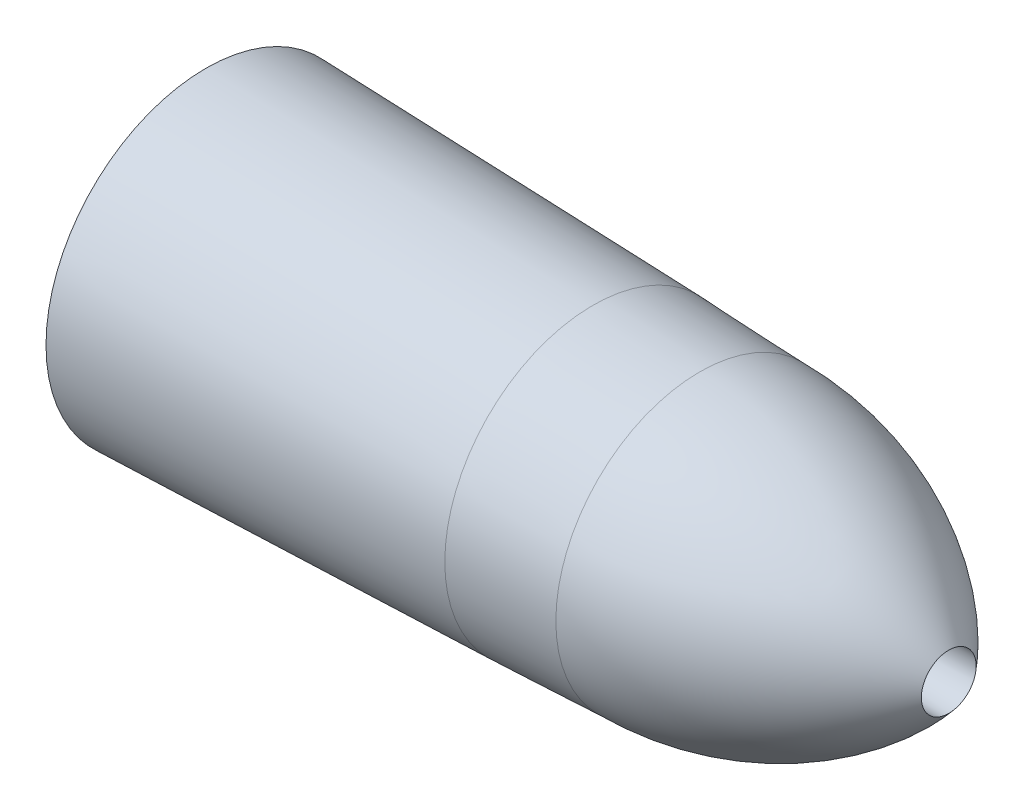
from build123d import *


with BuildPart() as part:
    # Sketch1 → Revolve1 (revolve)
    with BuildSketch(Plane(origin=(0, 0, 0), x_dir=(1, 0, 0), z_dir=(0, 1, 0))):
        Polygon((-355, 76.3943727), (-355, 12.3), (-170, 12.716901408), (-170, 70.8239497), align=None)
        Polygon((-170, 70.8239497), (-170, 12.716901408), (-119, 12.831830986), (-119, 68.7549354), align=None)
        with BuildLine():
            Line((-119, 68.7549354), (-119, 12.831830986))
            Line((-119, 12.831830986), (0, 13.1))
            ThreePointArc((0, 13.1), (-53.314248435, 54.153687996), (-119, 68.7549354))
        make_face()
    revolve(axis=Axis((-69.290541893, 0, 0), (1, 0, 0)))


solid = part.part
